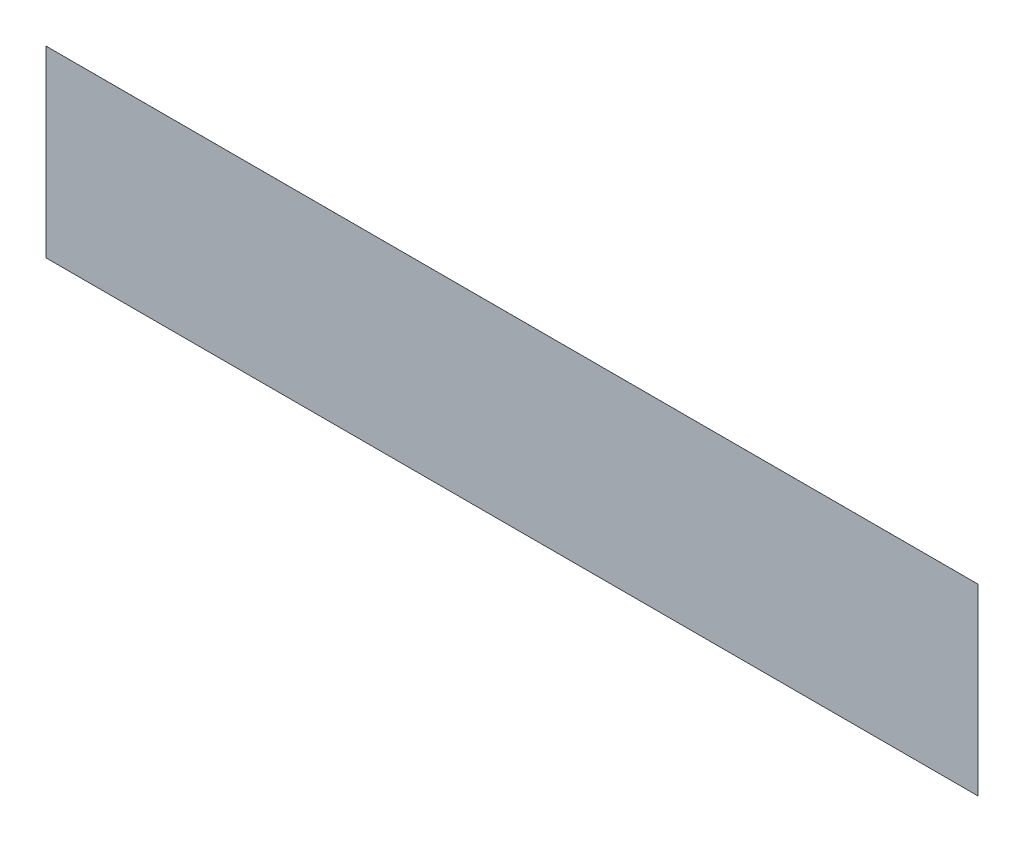
from build123d import *

# Parameters (mm, degrees)
SKETCH2_W           = 6096
SKETCH2_H           = 1200
BOSS_EXTRUDE1_DEPTH = 0.1


with BuildPart() as part:
    # Sketch2 → Boss-Extrude1 (new body)
    with BuildSketch(Plane.XY):
        with Locations((55.857474561, 2081.649176099)):
            Rectangle(SKETCH2_W, SKETCH2_H)
    extrude(amount=BOSS_EXTRUDE1_DEPTH)


solid = part.part
